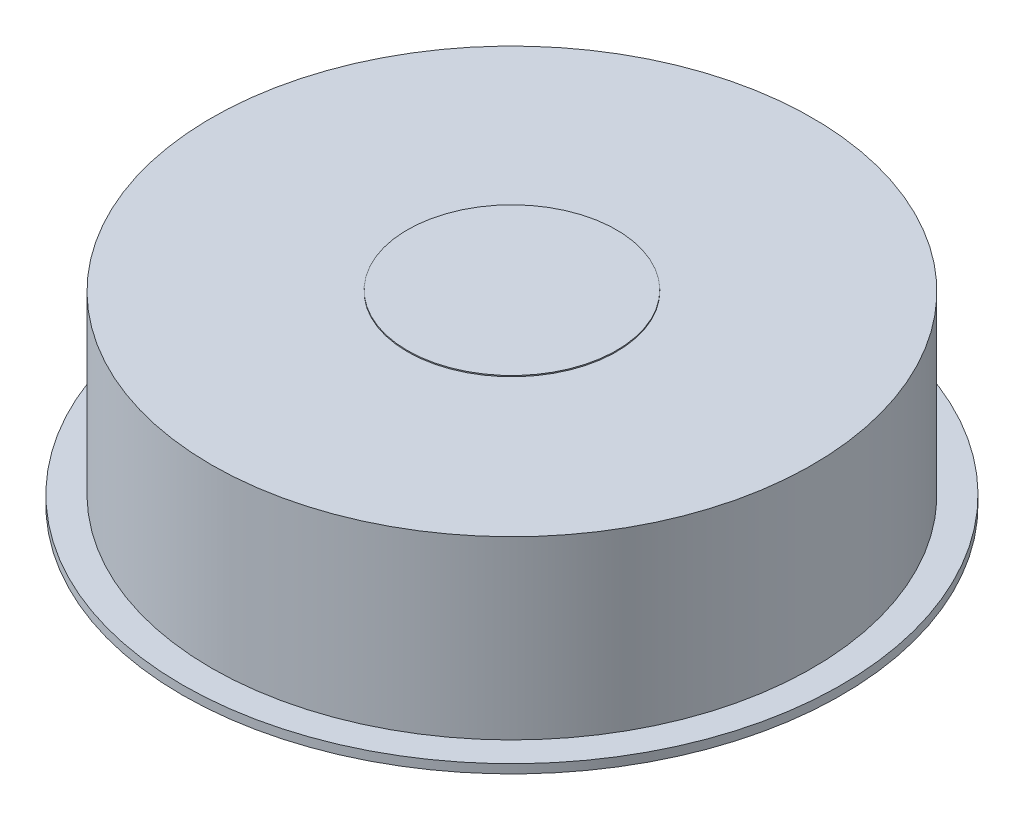
from build123d import *

# Parameters (mm, degrees)
SKETCH1_R           = 61.3
BOSS_EXTRUDE1_DEPTH = 1.65
SKETCH2_R           = 55.89
BOSS_EXTRUDE2_DEPTH = 32.735
SKETCH3_R           = 50.86
CUT_EXTRUDE1_DEPTH  = 14.35
SKETCH5_R           = 19.45
BOSS_EXTRUDE3_DEPTH = 0.2
SCALE2_SCALE        = 0.5


with BuildPart() as part:
    # Sketch1 → Boss-Extrude1 (new body)
    with BuildSketch(Plane(origin=(0, 0, 0), x_dir=(1, 0, 0), z_dir=(0, 1, 0))):
        Circle(SKETCH1_R)
    extrude(amount=BOSS_EXTRUDE1_DEPTH)

    # Sketch2 → Boss-Extrude2 (add)
    with BuildSketch(Plane(origin=(0, 1.65, 0), x_dir=(1, 0, 0), z_dir=(0, 1, 0))):
        Circle(SKETCH2_R)
    extrude(amount=BOSS_EXTRUDE2_DEPTH)

    # Sketch3 → Cut-Extrude1 (cut)
    with BuildSketch(Plane.XZ):
        Circle(SKETCH3_R)
    extrude(amount=-CUT_EXTRUDE1_DEPTH, mode=Mode.SUBTRACT)

    # Sketch5 → Boss-Extrude3 (add)
    with BuildSketch(Plane(origin=(0, 34.385, 0), x_dir=(1, 0, 0), z_dir=(0, 1, 0))):
        Circle(SKETCH5_R)
    extrude(amount=BOSS_EXTRUDE3_DEPTH)


with BuildPart() as part_1:
    # Scale2: scaled about (0, 22.178245993, 0)
    add(part.part.scale(SCALE2_SCALE).moved(Location((0, 11.089122997, 0))))


solid = part_1.part
